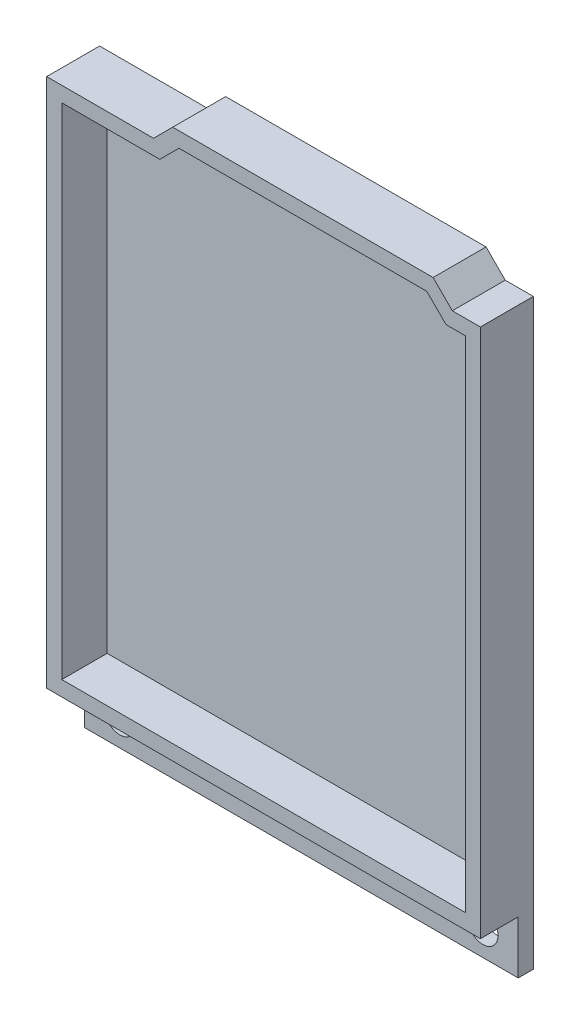
from build123d import *

# Parameters (mm, degrees)
BOSS_EXTRUDE1_DEPTH = 7
BOSS_EXTRUDE2_DEPTH = 1
SKETCH3_W           = 57.34
SKETCH3_H           = 7
BOSS_EXTRUDE3_DEPTH = 2
SKETCH4_R           = 2
CUT_EXTRUDE1_DEPTH  = 2


with BuildPart() as part:
    # Sketch1 → Boss-Extrude1 (new body)
    with BuildSketch(Plane.XY):
        Polygon((2, -2), (-55.34, -2), (-55.34, 68.04), (-41.214427125, 68.04), (-38.674427125, 70.58), (-4.251572875, 70.58), (-1.711572875, 68.04), (2, 68.04), align=None)
        Polygon((-53.34, 0), (-53.34, 66.04), (-40.386, 66.04), (-37.846, 68.58), (-5.08, 68.58), (-2.54, 66.04), (0, 66.04), (0, 0), align=None, mode=Mode.SUBTRACT)
    extrude(amount=-BOSS_EXTRUDE1_DEPTH)

    # Sketch2 → Boss-Extrude2 (add)
    with BuildSketch(Plane(origin=(0, 0, -7), x_dir=(-1, 0, 0), z_dir=(0, 0, -1))):
        Polygon((53.34, 0), (0, 0), (0, 66.04), (2.54, 66.04), (5.08, 68.58), (37.846, 68.58), (40.386, 66.04), (53.34, 66.04), align=None)
    extrude(amount=-BOSS_EXTRUDE2_DEPTH)

    # Sketch3 → Boss-Extrude3 (add)
    with BuildSketch(Plane(origin=(0, 0, -7), x_dir=(-1, 0, 0), z_dir=(0, 0, -1))):
        with Locations((26.67, -5.5)):
            Rectangle(SKETCH3_W, SKETCH3_H)
    extrude(amount=-BOSS_EXTRUDE3_DEPTH)

    # Sketch4 → Cut-Extrude1 (cut)
    with BuildSketch(Plane.XY.offset(-5)):
        with Locations((-2.67, -5.5)):
            Circle(SKETCH4_R)
        with Locations((-50.67, -5.5)):
            Circle(SKETCH4_R)
    extrude(amount=-CUT_EXTRUDE1_DEPTH, mode=Mode.SUBTRACT)


solid = part.part
